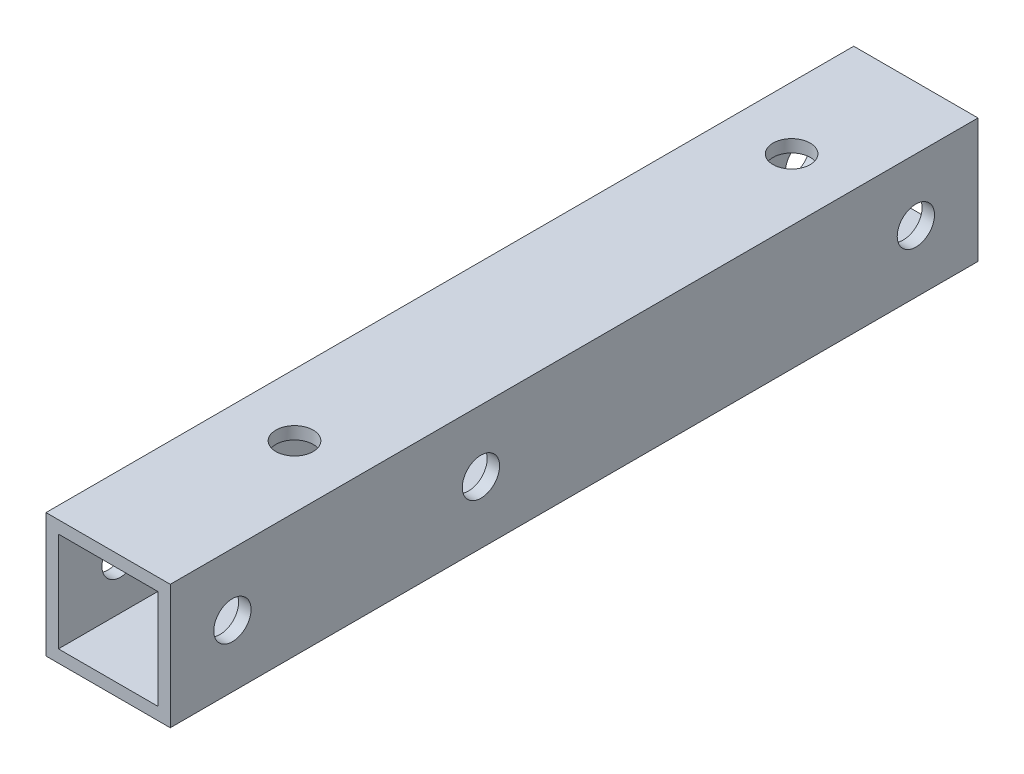
from build123d import *

# Parameters (mm, degrees)
SKETCH_1_W          = 10
SKETCH_1_H          = 10
SKETCH_1_W_2        = 8
SKETCH_1_H_2        = 8
EXTRUDE_1_DEPTH     = 65
SKETCH_2_R          = 1.5
CUT_EXTRUDE_1_DEPTH = 11
SKETCH_5_R          = 1.5
CUT_EXTRUDE_2_DEPTH = 11
CUT_EXTRUDE_START   = -5
SKETCH_6_R          = 3.5
CUT_EXTRUDE_3_DEPTH = 5


with BuildPart() as part:
    # 草图1 → 拉伸-薄壁1 (new body)
    with BuildSketch(Plane.XY):
        Rectangle(SKETCH_1_W, SKETCH_1_H)
        Rectangle(SKETCH_1_W_2, SKETCH_1_H_2, mode=Mode.SUBTRACT)
    extrude(amount=EXTRUDE_1_DEPTH)

    # 草图2 → 切除-拉伸1 (cut, through all)
    with BuildSketch(Plane.ZY.offset(5)):
        with Locations((40, 0)):
            Circle(SKETCH_2_R)
        with Locations((60, 0)):
            Circle(SKETCH_2_R)
        with Locations((5, 0)):
            Circle(SKETCH_2_R)
    extrude(amount=-CUT_EXTRUDE_1_DEPTH, mode=Mode.SUBTRACT)

    # 草图5 → 切除-拉伸2 (cut, through all)
    with BuildSketch(Plane(origin=(0, 5, 0), x_dir=(1, 0, 0), z_dir=(0, 1, 0))):
        with Locations((0, -10)):
            Circle(SKETCH_5_R)
        with Locations((0, -50)):
            Circle(SKETCH_5_R)
    extrude(amount=-CUT_EXTRUDE_2_DEPTH, mode=Mode.SUBTRACT)

    # 草图6 → 切除-拉伸3 (cut)
    with BuildSketch(Plane(origin=(0, 5, 0), x_dir=(1, 0, 0), z_dir=(0, 1, 0)).offset(CUT_EXTRUDE_START)):
        with Locations((0, -10)):
            Circle(SKETCH_6_R)
        with Locations((0, -50)):
            Circle(SKETCH_6_R)
    extrude(amount=-CUT_EXTRUDE_3_DEPTH, mode=Mode.SUBTRACT)


solid = part.part
